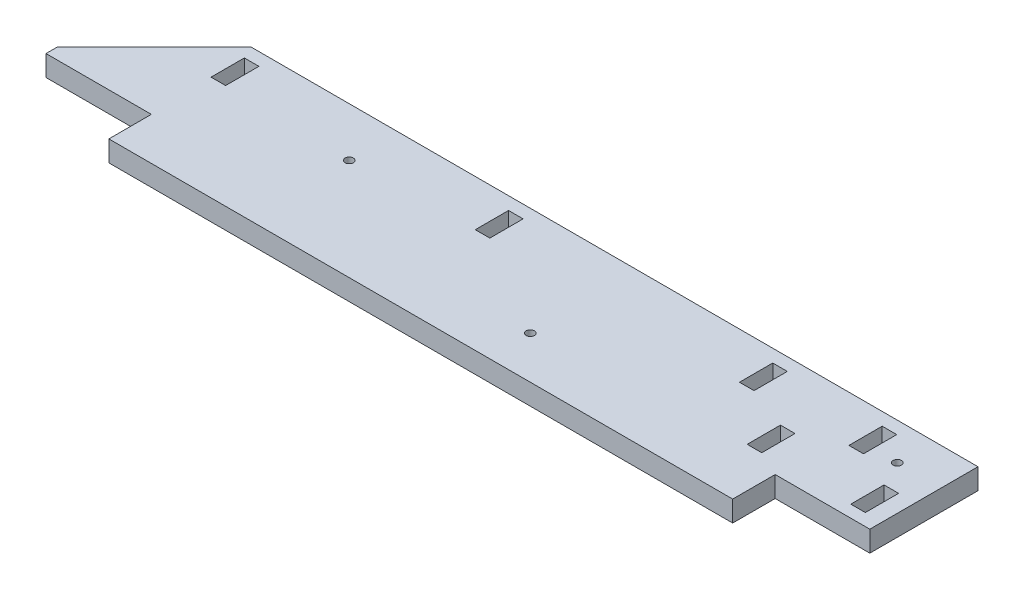
from build123d import *

# Parameters (mm, degrees)
SKETCH1_W           = 251.46
SKETCH1_H           = 33.02
BOSS_EXTRUDE1_DEPTH = 3.175
CUT_EXTRUDE1_DEPTH  = 7.35
SKETCH3_W           = 190.412642411
SKETCH3_H           = 12.967021693
BOSS_EXTRUDE2_DEPTH = 6.35
SKETCH5_R           = 1.2573
CUT_EXTRUDE2_DEPTH  = 7.35
SKETCH6_W           = 4.445
SKETCH6_H           = 10.16
CUT_EXTRUDE4_DEPTH  = 7.35


with BuildPart() as part:
    # Sketch1 → Boss-Extrude1 (new body, symmetric)
    with BuildSketch(Plane(origin=(0, 0, 0), x_dir=(1, 0, 0), z_dir=(0, 1, 0))):
        Rectangle(SKETCH1_W, SKETCH1_H)
    extrude(amount=BOSS_EXTRUDE1_DEPTH, both=True)

    # Sketch2 → Cut-Extrude1 (cut, through all)
    with BuildSketch(Plane.XZ.offset(3.175)):
        Polygon((-96.266, -16.51), (-125.73, 12.954), (-125.73, -16.51), align=None)
    extrude(amount=-CUT_EXTRUDE1_DEPTH, mode=Mode.SUBTRACT)

    # Sketch3 → Boss-Extrude2 (add)
    with BuildSketch(Plane(origin=(0, 3.175, 0), x_dir=(1, 0, 0), z_dir=(0, 1, 0))):
        with Locations((1.633403272, -22.993510847)):
            Rectangle(SKETCH3_W, SKETCH3_H)
    extrude(amount=-BOSS_EXTRUDE2_DEPTH)

    # Sketch5 → Cut-Extrude2 (cut, through all)
    with BuildSketch(Plane(origin=(0, 3.175, 0), x_dir=(1, 0, 0), z_dir=(0, 1, 0))):
        with Locations((112.3696, 5.2324)):
            Circle(SKETCH5_R)
        with Locations((22.098, -16.51)):
            Circle(SKETCH5_R)
        with Locations((-51.2064, 1.524)):
            Circle(SKETCH5_R)
    extrude(amount=-CUT_EXTRUDE2_DEPTH, mode=Mode.SUBTRACT)

    # Sketch6 → Cut-Extrude4 (cut, through all)
    with BuildSketch(Plane.XZ.offset(3.175)):
        with Locations((86.8045, 7.721036343)):
            Rectangle(SKETCH6_W, SKETCH6_H)
        with Locations((118.4275, 7.721036343)):
            Rectangle(SKETCH6_W, SKETCH6_H)
        with Locations((102.616, -7.518963657)):
            Rectangle(SKETCH6_W, SKETCH6_H)
        with Locations((69.215, -7.518963657)):
            Rectangle(SKETCH6_W, SKETCH6_H)
        with Locations((-11.43, -7.518963657)):
            Rectangle(SKETCH6_W, SKETCH6_H)
        with Locations((-92.075, -7.518963657)):
            Rectangle(SKETCH6_W, SKETCH6_H)
    extrude(amount=-CUT_EXTRUDE4_DEPTH, mode=Mode.SUBTRACT)


solid = part.part
